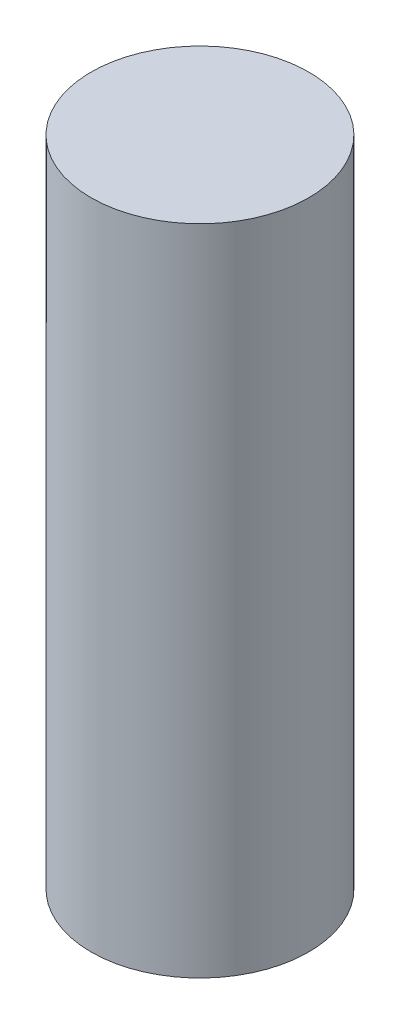
from build123d import *

# Parameters (mm, degrees)
SKETCH1_R                           = 1.5875
BOSS_EXTRUDE1_DEPTH                 = 9.525
F_5_64_0_07813_DIAMETER_HOLE1_D     = 1.984502
F_5_64_0_07813_DIAMETER_HOLE1_DEPTH = 5.08
F_5_64_0_07813_DIAMETER_HOLE1_TIP   = 0.59620455


with BuildPart() as part:
    # Sketch1 → Boss-Extrude1 (new body)
    with BuildSketch(Plane(origin=(0, 0, 0), x_dir=(1, 0, 0), z_dir=(0, 1, 0))):
        Circle(SKETCH1_R)
    extrude(amount=BOSS_EXTRUDE1_DEPTH)

    # 5/64 (0.07813) Diameter Hole1
    with Locations(Plane(origin=(0, 0, 0), x_dir=(-1, 0, 0), z_dir=(0, -1, 0))):
        with Locations((0, 0)):
            Hole(F_5_64_0_07813_DIAMETER_HOLE1_D / 2, depth=F_5_64_0_07813_DIAMETER_HOLE1_DEPTH)
            with Locations((0, 0, -(F_5_64_0_07813_DIAMETER_HOLE1_DEPTH + F_5_64_0_07813_DIAMETER_HOLE1_TIP / 2))):  # 118° drill point
                Cone(0, F_5_64_0_07813_DIAMETER_HOLE1_D / 2, F_5_64_0_07813_DIAMETER_HOLE1_TIP, mode=Mode.SUBTRACT)


solid = part.part
